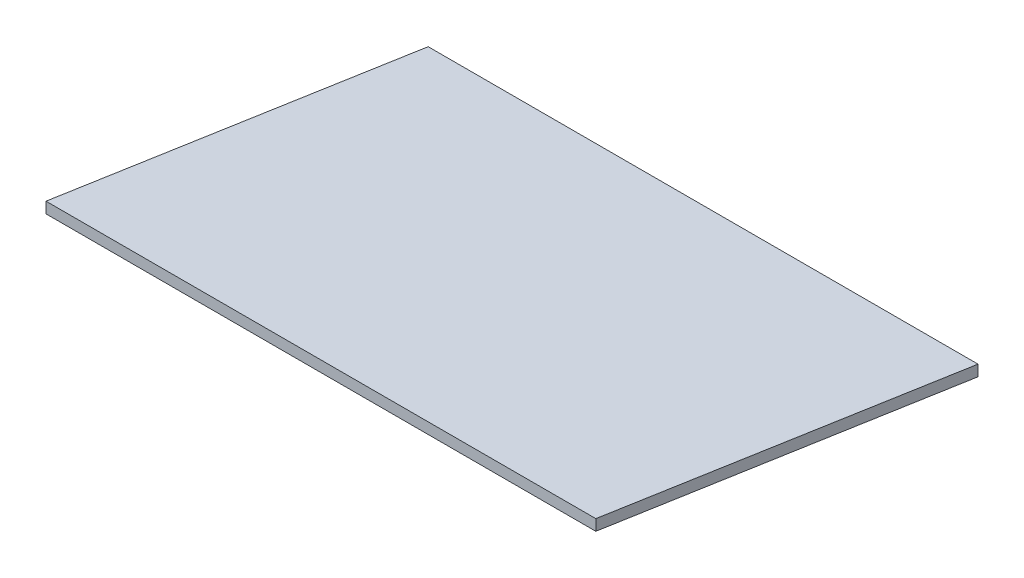
from build123d import *

# Parameters (mm, degrees)
PLATTE_DEPTH = 20


with BuildPart() as part:
    # Kontur Platte → Platte (new body)
    with BuildSketch(Plane(origin=(0, 0, 0), x_dir=(1, 0, 0), z_dir=(0, 1, 0))):
        with BuildLine():
            add(Edge.make_bspline(
                [(0, 0), (104.1889066, 590.884651807)],
                knots=[0, 0, 1, 1], degree=1))
            add(Edge.make_bspline(
                [(104.1889066, 590.884651807), (804.1889066, 590.884651807), (1104.1889066, 590.884651807)],
                knots=[0, 0, 0, 1, 1, 1], degree=2))
            add(Edge.make_bspline(
                [(1104.1889066, 590.884651807), (1000, 0)],
                knots=[0, 0, 1, 1], degree=1))
            add(Edge.make_bspline(
                [(1000, 0), (800, 0), (200, 0), (0, 0)],
                knots=[0, 0, 0, 0, 1, 1, 1, 1], degree=3))
        make_face()
    extrude(amount=PLATTE_DEPTH)


solid = part.part
